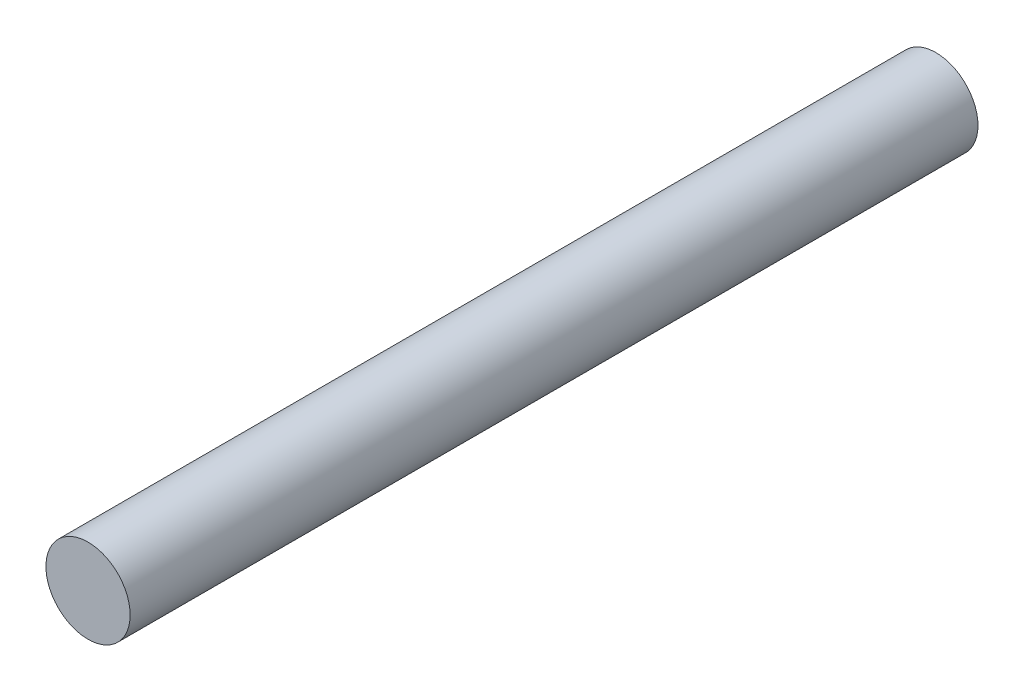
from build123d import *

# Parameters (mm, degrees)
SKETCH1_R           = 3.725
BOSS_EXTRUDE1_DEPTH = 75


with BuildPart() as part:
    # Sketch1 → Boss-Extrude1 (new body)
    with BuildSketch(Plane.XY):
        Circle(SKETCH1_R)
    extrude(amount=BOSS_EXTRUDE1_DEPTH)


solid = part.part
